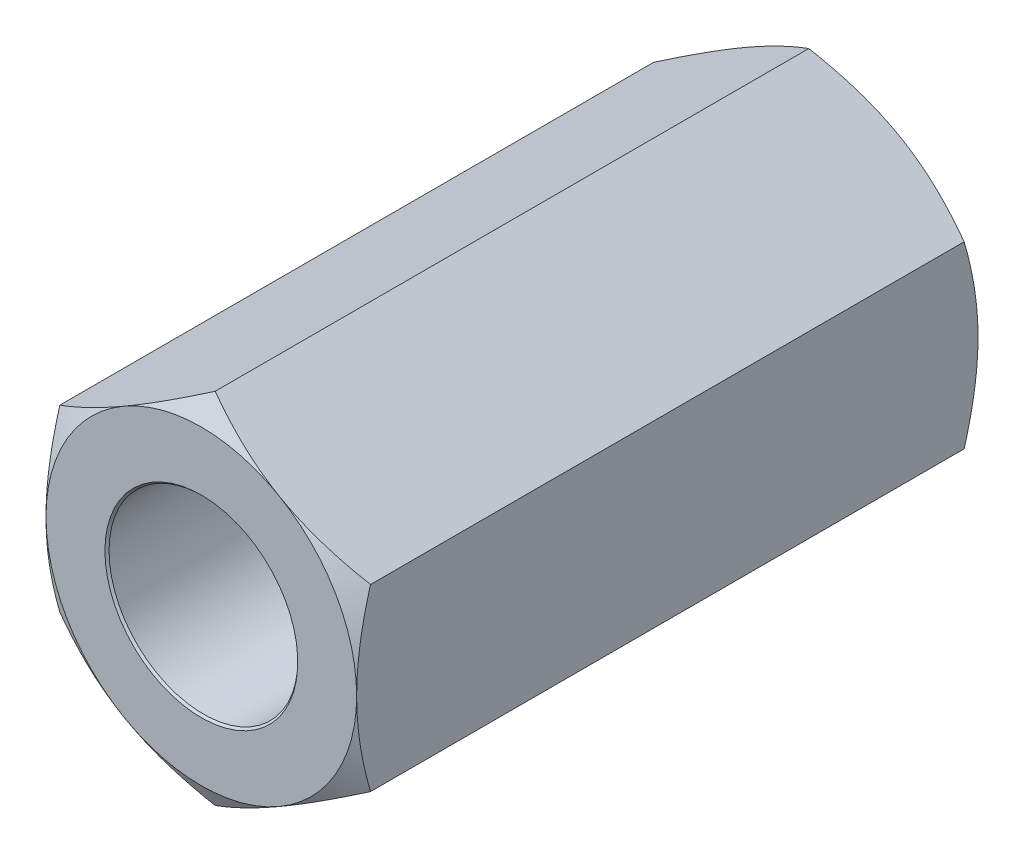
from build123d import *

# Parameters (mm, degrees)
EXTRUDE1_DEPTH          = 7.9375
EXTRUDE1_DEPTH_BACK     = 7.9375
SKETCH1_R               = 2.413
SKETCH8_OUTSIDE_W       = 76.264
SKETCH8_OUTSIDE_H       = 77.492
SKETCH8_OUTSIDE_R       = 3.96875
EXTRUDE4_DEPTH          = 17.993172266
EXTRUDE4_DRAFT          = -60
MIRROR1_COPY_1_SKETCH_W = 76.264
MIRROR1_COPY_1_SKETCH_H = 77.492
MIRROR1_COPY_1_SKETCH_R = 3.96875
MIRROR1_COPY_1_DEPTH    = 17.993172266
MIRROR1_COPY_1_DRAFT    = -60


with BuildPart() as part:
    # Sketch1 → Extrude1 (new, two sides: drawn at the far end of the back side and taken through both)
    with BuildSketch(Plane.XY.offset(-EXTRUDE1_DEPTH_BACK)):
        Polygon((0, 4.582717762), (-3.96875, 2.291358881), (-3.96875, -2.291358881), (0, -4.582717762), (3.96875, -2.291358881), (3.96875, 2.291358881), align=None)
        Circle(SKETCH1_R, mode=Mode.SUBTRACT)
    extrude(amount=EXTRUDE1_DEPTH + EXTRUDE1_DEPTH_BACK)

    # Extrude3 cone 1 section (through the dimple's axis) → Extrude3 (revolve, cut)
    with BuildSketch(Plane(origin=(0, 0, -7.9375), x_dir=(0, 1, 0), z_dir=(1, 0, 0))):
        Polygon((0, 0), (2.4638, 0), (0, 2.642102028), align=None)
    extrude3 = revolve(axis=Axis((0, 0, -7.9375), (0, 0, 1)), mode=Mode.SUBTRACT)


with BuildPart() as extrude4_tool:
    # Sketch8 outside → Extrude4 (with draft: the straight prism first)
    with BuildSketch(Plane(origin=(0, 0, -7.9375), x_dir=(-1, 0, 0), z_dir=(0, 0, -1))):
        Rectangle(SKETCH8_OUTSIDE_W, SKETCH8_OUTSIDE_H)
        Circle(SKETCH8_OUTSIDE_R, mode=Mode.SUBTRACT)
    extrude(amount=-EXTRUDE4_DEPTH)
    # Extrude4: the draft: its side faces are tilted about the plane it starts from
    extrude4_sides = [extrude4_tool.faces().sort_by_distance(p)[0] for p in [
        (0, -38.746, 1.059086133),
        (-38.132, 0, 1.059086133),
        (0, 38.746, 1.059086133),
        (38.132, 0, 1.059086133),
        (3.96875, 0, 1.059086133),
    ]]
    draft(extrude4_sides, Plane(origin=(0, 0, -7.9375), x_dir=(-1, 0, 0), z_dir=(0, 0, -1)), EXTRUDE4_DRAFT)


with BuildPart() as part_1:
    add(part.part)

    # Extrude4: cut by extrude4_tool
    add(extrude4_tool.part, mode=Mode.SUBTRACT)

    # Mirror1: Extrude3 across plane
    add(extrude3.mirror(Plane.XY), mode=Mode.SUBTRACT)


with BuildPart() as mirror1_copy_1_tool:
    # Mirror1 copy 1 sketch → Mirror1 copy 1 (with draft: the straight prism first)
    with BuildSketch(Plane(origin=(0, 0, 7.9375), x_dir=(-1, 0, 0), z_dir=(0, 0, 1))):
        Rectangle(MIRROR1_COPY_1_SKETCH_W, MIRROR1_COPY_1_SKETCH_H)
        Circle(MIRROR1_COPY_1_SKETCH_R, mode=Mode.SUBTRACT)
    extrude(amount=-MIRROR1_COPY_1_DEPTH)
    # Mirror1 copy 1: the draft: its side faces are tilted about the plane it starts from
    mirror1_copy_1_sides = [mirror1_copy_1_tool.faces().sort_by_distance(p)[0] for p in [
        (0, -38.746, -1.059086133),
        (-38.132, 0, -1.059086133),
        (0, 38.746, -1.059086133),
        (38.132, 0, -1.059086133),
        (3.96875, 0, -1.059086133),
    ]]
    draft(mirror1_copy_1_sides, Plane(origin=(0, 0, 7.9375), x_dir=(-1, 0, 0), z_dir=(0, 0, 1)), MIRROR1_COPY_1_DRAFT)


with BuildPart() as part_2:
    add(part_1.part)

    # Mirror1 copy 1: cut by mirror1_copy_1_tool
    add(mirror1_copy_1_tool.part, mode=Mode.SUBTRACT)


solid = part_2.part
